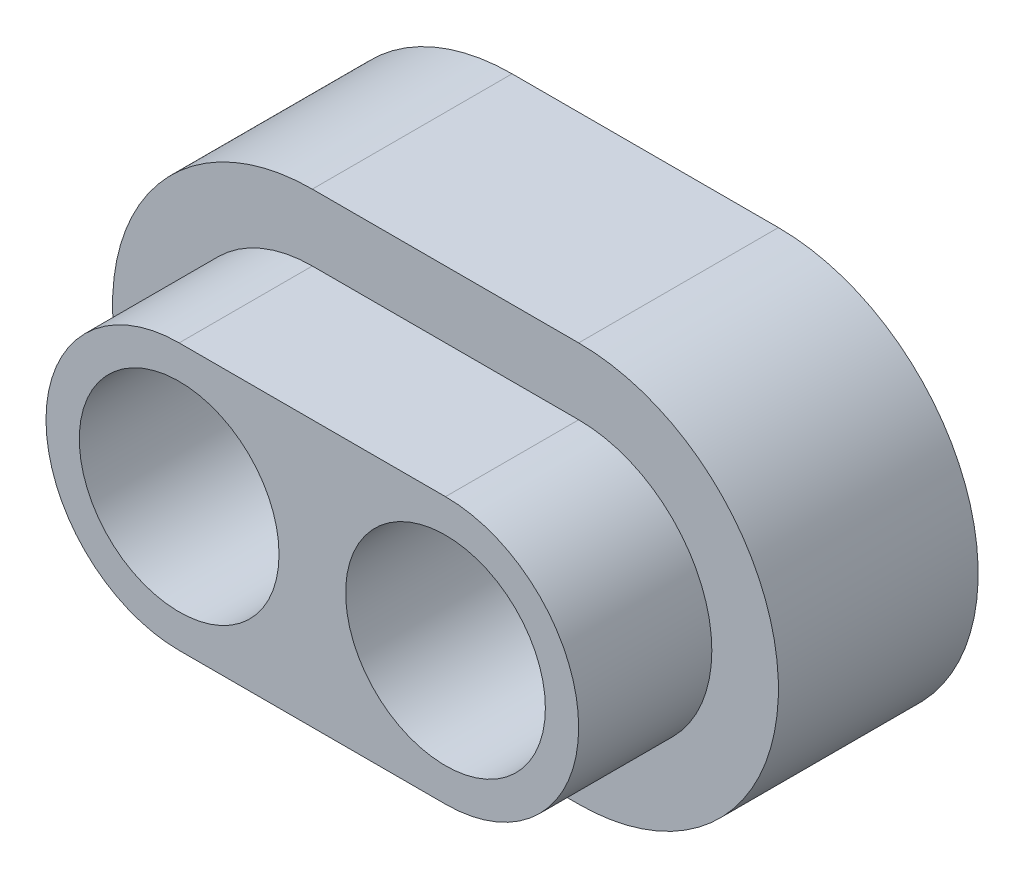
from build123d import *

# Parameters (mm, degrees)
SKETCH_1_R          = 3
SKETCH_1_W          = 4
SKETCH_1_H          = 6
EXTRUDE_1_DEPTH     = 3
SKETCH_1_4_R        = 2
SKETCH_1_4_W        = 4
SKETCH_1_4_H        = 4
EXTRUDE_2_DEPTH     = 5
SKETCH_1_5_R        = 1.5
CUT_EXTRUDE_1_DEPTH = 6


with BuildPart() as part:
    # Sketch 1 → Extrude 1 (new body)
    with BuildSketch(Plane.XY):
        with Locations((-2, 0)):
            Circle(SKETCH_1_R)
        with Locations((2, 0)):
            Circle(SKETCH_1_R)
        Rectangle(SKETCH_1_W, SKETCH_1_H)
    extrude(amount=EXTRUDE_1_DEPTH)

    # Sketch 1_4 → Extrude 2 (add)
    with BuildSketch(Plane.XY):
        with Locations((-2, 0)):
            Circle(SKETCH_1_4_R)
        with Locations((2, 0)):
            Circle(SKETCH_1_4_R)
        Rectangle(SKETCH_1_4_W, SKETCH_1_4_H)
    extrude(amount=EXTRUDE_2_DEPTH)

    # Sketch 1_5 → Cut-Extrude 1 (cut, through all)
    with BuildSketch(Plane.XY):
        with Locations((-2, 0)):
            Circle(SKETCH_1_5_R)
        with Locations((2, 0)):
            Circle(SKETCH_1_5_R)
    extrude(amount=CUT_EXTRUDE_1_DEPTH, mode=Mode.SUBTRACT)


solid = part.part
